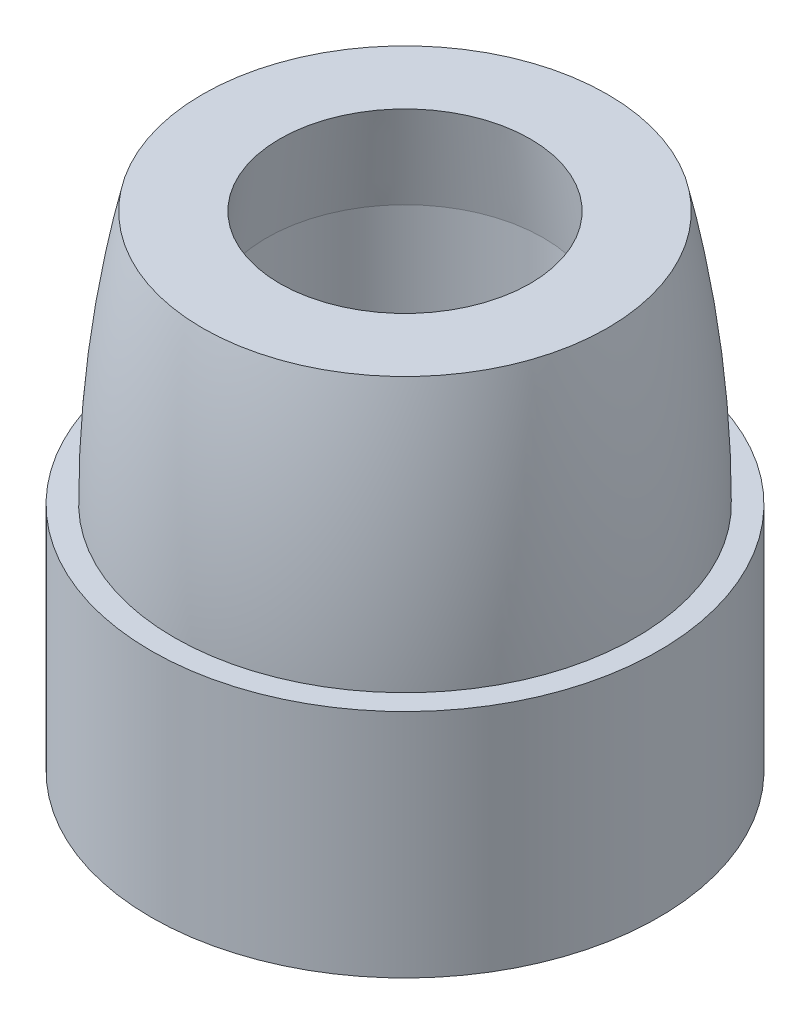
from build123d import *

# Parameters (mm, degrees)
SKETCH_2_R          = 4
CUT_EXTRUDE_1_DEPTH = 4
SKETCH_3_R          = 5.5
SKETCH_3_R_2        = 2.5
CUT_EXTRUDE_2_DEPTH = 1.5


with BuildPart() as part:
    # Эскиз1 → Повернуть1 (revolve)
    with BuildSketch(Plane.XY):
        with BuildLine():
            Line((3, 0), (5.5, 0))
            Line((5.5, 0), (5.5, 5))
            Line((5.5, 5), (5, 5))
            ThreePointArc((5, 5), (4.748737342, 8.535533906), (4, 12))
            Line((4, 12), (2.5, 12))
            Line((2.5, 12), (3, 8.5))
            Line((3, 8.5), (3, 0))
        make_face()
    revolve(axis=Axis((0, 0, 0), (0, 1, 0)))

    # Эскиз2 → Вырез-Вытянуть1 (cut)
    with BuildSketch(Plane.XZ):
        Circle(SKETCH_2_R)
    extrude(amount=-CUT_EXTRUDE_1_DEPTH, mode=Mode.SUBTRACT)

    # Эскиз3 → Вырез-Вытянуть2 (cut)
    with BuildSketch(Plane(origin=(0, 12, 0), x_dir=(1, 0, 0), z_dir=(0, 1, 0))):
        Circle(SKETCH_3_R)
        Circle(SKETCH_3_R_2, mode=Mode.SUBTRACT)
    extrude(amount=-CUT_EXTRUDE_2_DEPTH, mode=Mode.SUBTRACT)


solid = part.part
